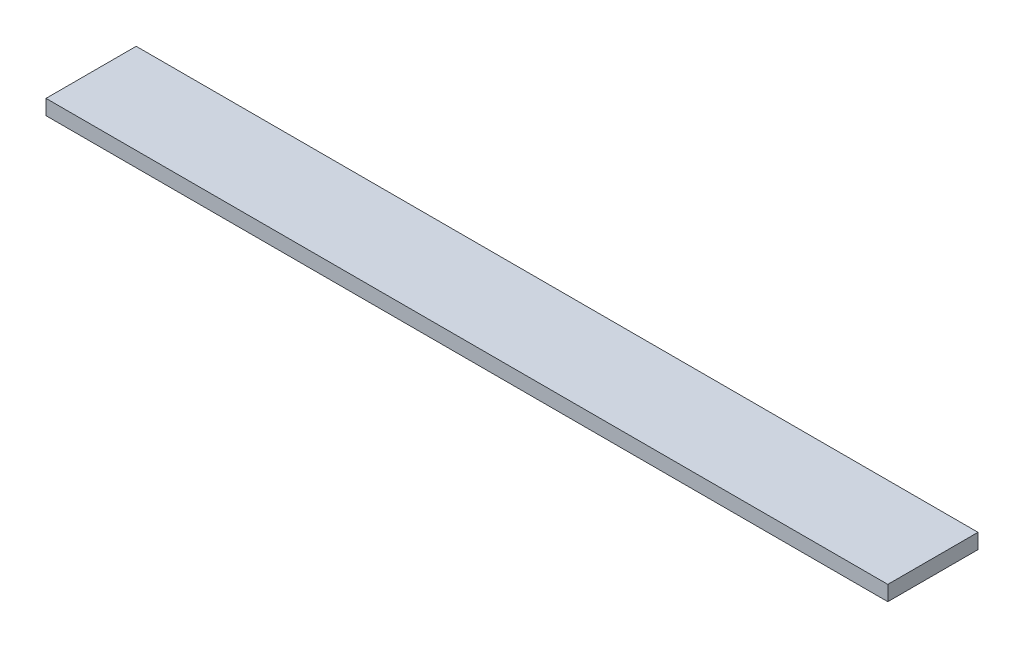
from build123d import *

# Parameters (mm, degrees)
SKETCH1_W           = 711.2
SKETCH1_H           = 76.2
BOSS_EXTRUDE1_DEPTH = 12.7


with BuildPart() as part:
    # Sketch1 → Boss-Extrude1 (new body)
    with BuildSketch(Plane(origin=(0, 0, 0), x_dir=(1, 0, 0), z_dir=(0, 1, 0))):
        with Locations((355.6, 38.1)):
            Rectangle(SKETCH1_W, SKETCH1_H)
    extrude(amount=BOSS_EXTRUDE1_DEPTH)


solid = part.part
